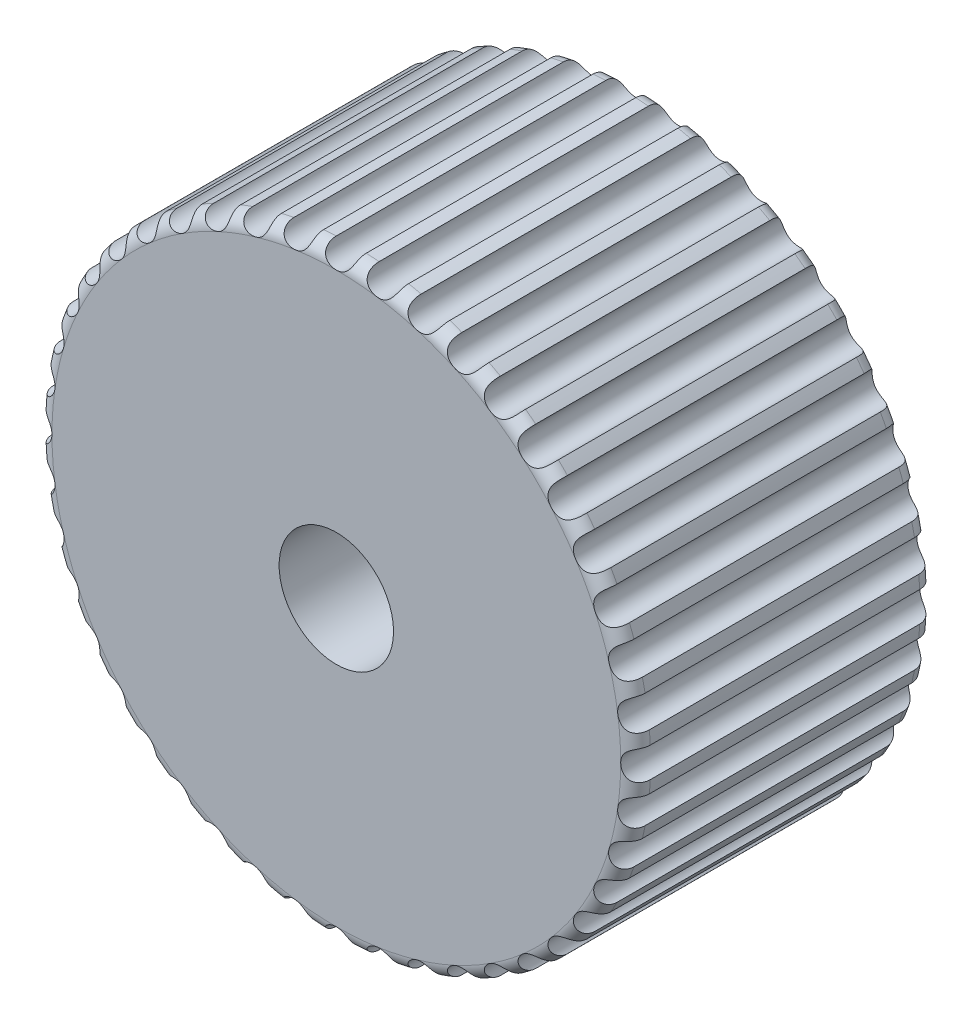
from build123d import *
from build123d.topology import SkipClean

# Parameters (mm, degrees)
SKETCH1_R           = 2
SKETCH1_R_2         = 0.38223259
BOSS_EXTRUDE1_DEPTH = 2
SKETCH1_2_R         = 0.38223259
BOSS_EXTRUDE2_DEPTH = 1
FILLET1_R           = 0.1
SKETCH2_R           = 0.1
CUT_EXTRUDE1_DEPTH  = 8.667536605
CIRPATTERN1_COUNT   = 44


with BuildPart() as part:
    # Sketch1 → Boss-Extrude1 (new body)
    with BuildSketch(Plane.XY):
        with Locations((1.350190497, -4.600555979)):
            Circle(SKETCH1_R)
        with Locations((1.350190497, -4.600555979)):
            Circle(SKETCH1_R_2, mode=Mode.SUBTRACT)
    extrude(amount=BOSS_EXTRUDE1_DEPTH)

    # Sketch1_2 → Boss-Extrude2 (add)
    with BuildSketch(Plane.XY):
        with Locations((1.350190497, -4.600555979)):
            Circle(SKETCH1_2_R)
    extrude(amount=BOSS_EXTRUDE2_DEPTH)

    # Fillet1
    fillet1_edges = [part.edges().sort_by_distance(p)[0] for p in [
        (-0.649809503, -4.600555979, 2),
        (-0.649809503, -4.600555979, 0),
    ]]
    fillet(fillet1_edges, radius=FILLET1_R)

    # Sketch2 → Cut-Extrude1 (cut, through all)
    with SkipClean():  # the faces are left unmerged after this step: merging them gives an invalid solid
        with BuildSketch(Plane(origin=(0, 0, 0), x_dir=(-1, 0, 0), z_dir=(0, 0, -1))):
            with Locations((-1.350190497, -2.600555979)):
                Circle(SKETCH2_R)
        cut_extrude1 = extrude(amount=-CUT_EXTRUDE1_DEPTH, mode=Mode.SUBTRACT)

    # CirPattern1: Cut-Extrude1 ×44 about axis
    cirpattern1_axis = Axis((1.350190497, -4.600555979, 2), (0, 0, -1))
    for i in range(1, CIRPATTERN1_COUNT):
        add(cut_extrude1.rotate(cirpattern1_axis, i * 360 / CIRPATTERN1_COUNT), mode=Mode.SUBTRACT)


solid = part.part
